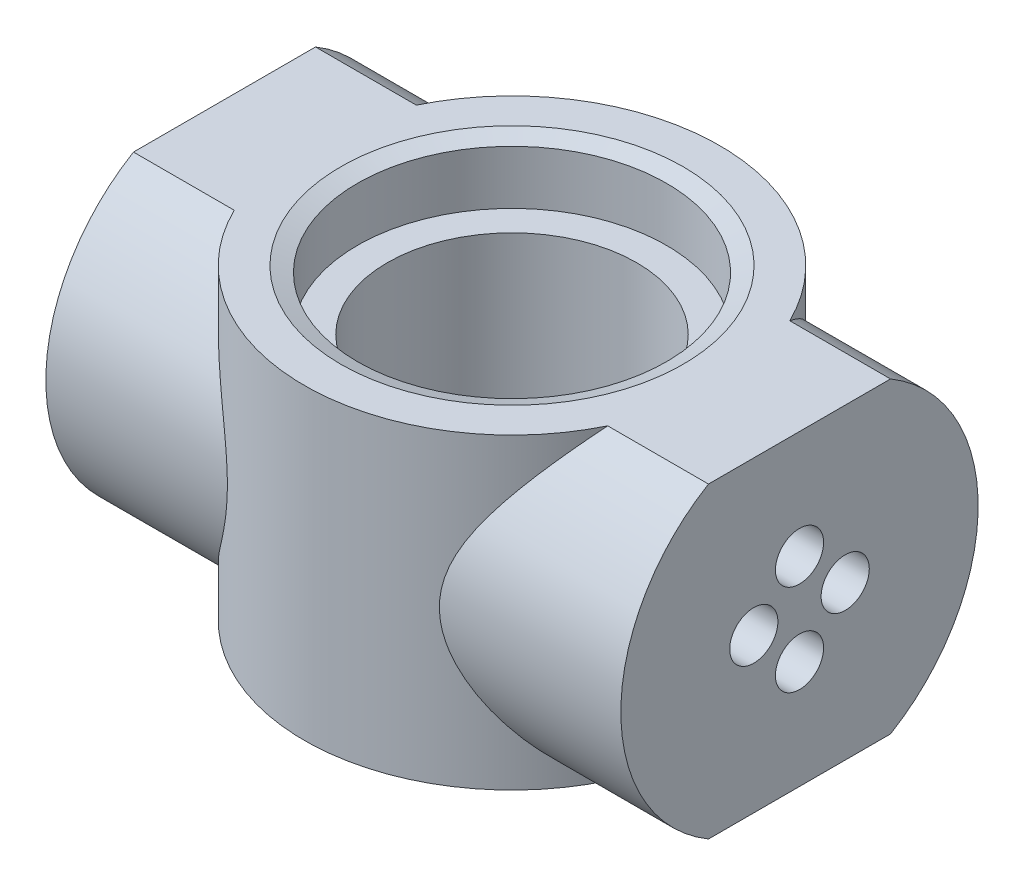
from build123d import *
from OCP.BRepFilletAPI import BRepFilletAPI_MakeChamfer
from build123d.topology import SkipClean

# Parameters (mm, degrees)
SKIZZE1_R                            = 25
SKIZZE1_R_2                          = 18.6
AUFSATZ_LINEAR_AUSTRAGEN1_DEPTH      = 18.5
SKIZZE2_R                            = 18.6
SKIZZE2_R_2                          = 15
AUFSATZ_LINEAR_AUSTRAGEN2_DEPTH      = 11.3
SKIZZE3_R                            = 21.5
AUFSATZ_LINEAR_AUSTRAGEN3_DEPTH      = 16
SKIZZE4_R                            = 2.9
SCHNITT_LINEAR_AUSTRAGEN1_DEPTH      = 9.1
SKIZZE5_OUTSIDE_W                    = 64.118
SKIZZE5_OUTSIDE_H                    = 71.118
SKIZZE5_OUTSIDE_W_2                  = 37
SKIZZE5_OUTSIDE_H_2                  = 50
SCHNITT_LINEAR_AUSTRAGEN2_DEPTH      = 67.342867843
SCHNITT_LINEAR_AUSTRAGEN2_DEPTH_BACK = 67.342867843
AUFSATZ_LINEAR_AUSTRAGEN4_DEPTH      = 37.2
SKIZZE8_R                            = 18.6
SCHNITT_LINEAR_AUSTRAGEN3_DEPTH      = 53.059581422
FASE1_SIZE                           = 2
FASE1_SIZE2                          = 0.727940469


with BuildPart() as part:
    # Skizze1 → Aufsatz-Linear austragen1 (new, symmetric)
    with BuildSketch(Plane(origin=(0, 0, 0), x_dir=(1, 0, 0), z_dir=(0, 1, 0))):
        with Locations(Location((0, 0, 0), (0, 0, 270))):
            Circle(SKIZZE1_R)
        with Locations(Location((0, 0, 0), (0, 0, 270))):
            Circle(SKIZZE1_R_2, mode=Mode.SUBTRACT)
    extrude(amount=AUFSATZ_LINEAR_AUSTRAGEN1_DEPTH, both=True)

    # Skizze2 → Aufsatz-Linear austragen2 (add, symmetric)
    with BuildSketch(Plane(origin=(0, 0, 0), x_dir=(1, 0, 0), z_dir=(0, 1, 0))):
        with Locations(Location((0, 0, 0), (0, 0, 270))):
            Circle(SKIZZE2_R)
        with Locations(Location((0, 0, 0), (0, 0, 270))):
            Circle(SKIZZE2_R_2, mode=Mode.SUBTRACT)
    extrude(amount=AUFSATZ_LINEAR_AUSTRAGEN2_DEPTH, both=True)

    # Skizze3 → Aufsatz-Linear austragen3 (add)
    with BuildSketch(Plane(origin=(18.6, 0, 0), x_dir=(0, 0, -1), z_dir=(1, 0, 0))):
        with Locations(Location((0, 0, 0), (0, 0, 140.982439232))):
            Circle(SKIZZE3_R)
    aufsatz_linear_austragen3 = extrude(amount=AUFSATZ_LINEAR_AUSTRAGEN3_DEPTH)

    # Skizze4 → Schnitt-Linear austragen1 (cut)
    with BuildSketch(Plane(origin=(34.6, 0, 0), x_dir=(0, 0, -1), z_dir=(1, 0, 0))):
        with Locations((-5.5, 0)):
            Circle(SKIZZE4_R)
        with Locations((0, 5.5)):
            Circle(SKIZZE4_R)
        with Locations((5.5, 0)):
            Circle(SKIZZE4_R)
        with Locations((0, -5.5)):
            Circle(SKIZZE4_R)
    schnitt_linear_austragen1 = extrude(amount=-SCHNITT_LINEAR_AUSTRAGEN1_DEPTH, mode=Mode.SUBTRACT)

    # Spiegeln1: Aufsatz-Linear austragen3, Schnitt-Linear austragen1 across plane
    add(aufsatz_linear_austragen3.mirror(Plane(origin=(0, 0, 0), x_dir=(0, 0, 1), z_dir=(1, 0, 0))))
    add(schnitt_linear_austragen1.mirror(Plane(origin=(0, 0, 0), x_dir=(0, 0, 1), z_dir=(1, 0, 0))), mode=Mode.SUBTRACT)

    # Skizze5 outside → Schnitt-Linear austragen2 (cut, two sides)
    with BuildSketch(Plane(origin=(0, 29.28598322, 0), x_dir=(0, -1, 0), z_dir=(-1, 0, 0))) as schnitt_linear_austragen2_sk:
        with Locations((29.286, 0)):
            Rectangle(SKIZZE5_OUTSIDE_W, SKIZZE5_OUTSIDE_H)
        with Locations((29.28598322, 0)):
            Rectangle(SKIZZE5_OUTSIDE_W_2, SKIZZE5_OUTSIDE_H_2, mode=Mode.SUBTRACT)
    extrude(amount=SCHNITT_LINEAR_AUSTRAGEN2_DEPTH, mode=Mode.SUBTRACT)
    extrude(schnitt_linear_austragen2_sk.sketch, amount=-SCHNITT_LINEAR_AUSTRAGEN2_DEPTH_BACK, mode=Mode.SUBTRACT)

    # Skizze7 → Aufsatz-Linear austragen4 (add)
    with BuildSketch(Plane.ZY.offset(-18.6)):
        with BuildLine():
            Line((16.704490414, 13.535508856), (16.704490414, -13.535508856))
            ThreePointArc((16.704490414, -13.535508856), (21.5, 0), (16.704490414, 13.535508856))
        make_face()
    aufsatz_linear_austragen4 = extrude(amount=AUFSATZ_LINEAR_AUSTRAGEN4_DEPTH)

    # Spiegeln2: Aufsatz-Linear austragen4 across plane
    add(aufsatz_linear_austragen4.mirror(Plane.XY))

    # Skizze8 → Schnitt-Linear austragen3 (cut, through all)
    with BuildSketch(Plane(origin=(0, 11.3, 0), x_dir=(1, 0, 0), z_dir=(0, 1, 0))):
        with Locations(Location((0, 0, 0), (0, 0, 100.458673289))):
            Circle(SKIZZE8_R)
    schnitt_linear_austragen3 = extrude(amount=SCHNITT_LINEAR_AUSTRAGEN3_DEPTH, mode=Mode.SUBTRACT)

    # Spiegeln3: Schnitt-Linear austragen3 across plane
    with SkipClean():  # the faces are left unmerged after this step: merging them gives an invalid solid
        add(schnitt_linear_austragen3.mirror(Plane.ZX), mode=Mode.SUBTRACT)

    # Fase1: one chamfer whose edges measure the first distance from different faces: ONE call of the kernel's chamfer builder (chamfer() names one face for all edges)
    fase1_edges_1 = [part.edges().sort_by_distance(p)[0] for p in [
        (18.522584239, -18.5, -1.695250166),
    ]]
    fase1_side_1 = [part.faces().sort_by_distance(p)[0] for p in [
        (18.522584239, -14.9, -1.695250166),
    ]]
    fase1_edges_2 = [part.edges().sort_by_distance(p)[0] for p in [
        (0, 18.5, -18.6),
    ]]
    fase1_side_2 = [part.faces().sort_by_distance(p)[0] for p in [
        (0, 18.5, 24.146264678),
    ]]
    fase1 = BRepFilletAPI_MakeChamfer(part.part.solid().wrapped)
    for e in fase1_edges_1:
        fase1.Add(FASE1_SIZE, FASE1_SIZE2, e.wrapped, fase1_side_1[0].wrapped)  # the first distance lies on this face
    for e in fase1_edges_2:
        fase1.Add(FASE1_SIZE, FASE1_SIZE2, e.wrapped, fase1_side_2[0].wrapped)  # the first distance lies on this face
    add(Compound.cast(fase1.Shape()), mode=Mode.REPLACE)


solid = part.part
